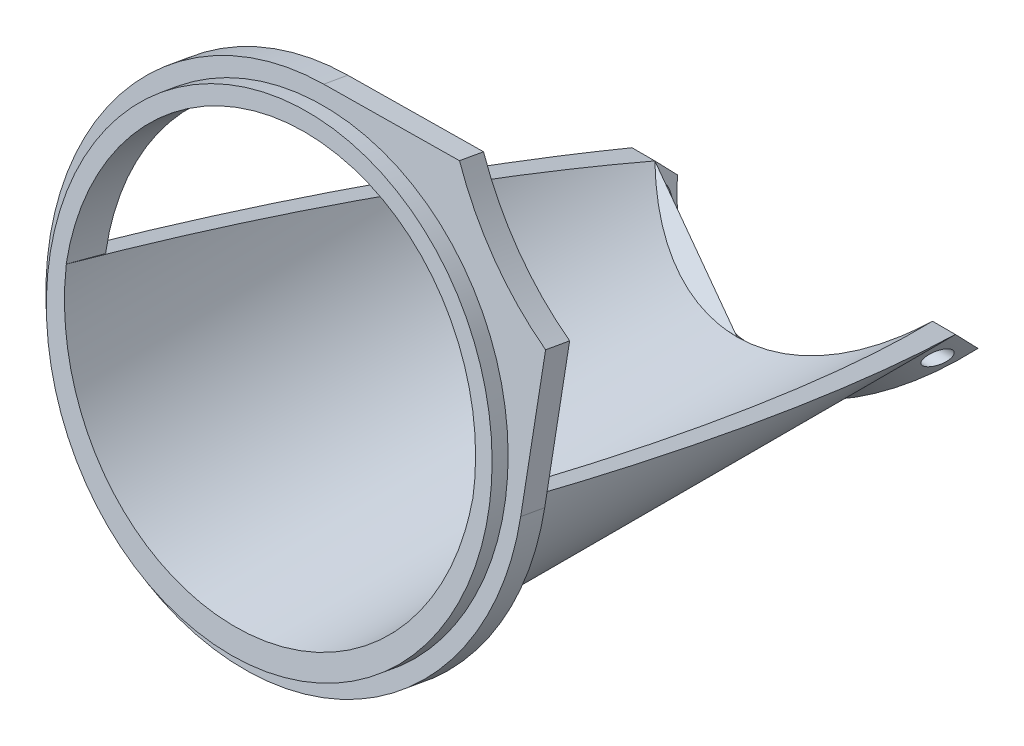
from build123d import *

# Parameters (mm, degrees)
MAIN_DEPTH                = 90
TOPSUPPORT_DEPTH          = 99.336158152
TOPSUPPORT_DEPTH_BACK     = 99.336158152
BACK_EXTRUSION_DEPTH      = 99.336158152
BACK_EXTRUSION_DEPTH_BACK = 99.336158152
BACK_DEPTH                = 4
SKETCH8_R                 = 1.25
ROLLINGHOLESUPPORT_DEPTH  = 25
SKETCH3_R                 = 27
SKETCH3_R_2               = 25
CIRCLEFIX_DEPTH           = 2
SKETCH5_R                 = 25
TRIANGLEFIX_DEPTH         = 3
SKETCH12_R                = 52.533480643
CUT_EXTRUDE2_DEPTH        = 85.444365438


with BuildPart() as part:
    # Sketch1 → Main (new body)
    with BuildSketch(Plane.XY):
        with BuildLine():
            Line((25, 27), (25, 29))
            Line((25, 29), (26.925824036, 29))
            ThreePointArc((26.925824036, 29), (0, 0), (-26.925824036, 29))
            Line((-26.925824036, 29), (-25, 29))
            Line((-25, 29), (-25, 27))
            ThreePointArc((-25, 27), (0, 2), (25, 27))
        make_face()
    extrude(amount=MAIN_DEPTH)

    # Sketch11 → TopSupport (cut, two sides: drawn at the far end of the back side and taken through both)
    with BuildSketch(Plane(origin=(0, 0, 0), x_dir=(0, 0, -1), z_dir=(1, 0, 0)).offset(-TOPSUPPORT_DEPTH_BACK)):
        Polygon((-84.886517559, 29), (0, 29), (0, 3.112986155), (-85.415498502, 26), align=None)
    extrude(amount=TOPSUPPORT_DEPTH + TOPSUPPORT_DEPTH_BACK, mode=Mode.SUBTRACT)

    # Sketch6 → Back-Extrusion (cut, two sides: drawn at the far end of the back side and taken through both)
    with BuildSketch(Plane(origin=(0, 0, 0), x_dir=(0, 0, -1), z_dir=(1, 0, 0)).offset(-BACK_EXTRUSION_DEPTH_BACK)):
        Polygon((0, 29), (0, 0), (-30, 0), align=None)
    extrude(amount=BACK_EXTRUSION_DEPTH + BACK_EXTRUSION_DEPTH_BACK, mode=Mode.SUBTRACT)

    # Sketch7 → Back (add)
    with BuildSketch(Plane(origin=(0, 14.991384262, 14.491671453), x_dir=(1, 0, 0), z_dir=(0, -0.7189883760491118, -0.6950220968474751))):
        with BuildLine():
            Line((19.880970173, 9.007093118), (17.066135327, 9.007093118))
            ThreePointArc((17.066135327, 9.007093118), (0, 18.69204493), (-17.066135327, 9.007093118))
            Line((-17.066135327, 9.007093118), (-19.880970173, 9.007093118))
            add(Edge.make_bspline(
                [(19.880970173, 9.007093118), (0, 40.117630414), (-19.880970173, 9.007093118)],
                knots=[5.456476318, 5.456476318, 5.456476318, 7.109894296, 7.109894296, 7.109894296], degree=2, weights=[1, 0.677300641, 1]))
        make_face()
    extrude(amount=BACK_DEPTH)

    # Sketch8 → RollingHoleSupport (cut, symmetric)
    with BuildSketch(Plane(origin=(0, 0, 0), x_dir=(0, 0, -1), z_dir=(1, 0, 0))):
        with Locations((-21.375093453, 5.555723522)):
            Circle(SKETCH8_R)
    extrude(amount=ROLLINGHOLESUPPORT_DEPTH, both=True, mode=Mode.SUBTRACT)

    # Sketch3 → CircleFix (add)
    with BuildSketch(Plane(origin=(0, 0.398226786, 89.929781873), x_dir=(1, 0, 0), z_dir=(0, 0.17364817766693072, 0.984807753012208))):
        with Locations((0, 25.80563308)):
            Circle(SKETCH3_R)
        with Locations((0, 25.80563308)):
            Circle(SKETCH3_R_2, mode=Mode.SUBTRACT)
    extrude(amount=-CIRCLEFIX_DEPTH)

    # Sketch5 → TriangleFix (add)
    with BuildSketch(Plane(origin=(0, 15.043610094, 85.316552429), x_dir=(-1, 0, 0), z_dir=(0, 0.17364817766693072, 0.9848077530122081))):
        with BuildLine():
            Line((0.29697859, -39.580146501), (-16.358158426, -39.750714725))
            ThreePointArc((-16.358158426, -39.750714725), (-21.920310217, -32.501977383), (-29.169047558, -26.939825592))
            Line((-29.169047558, -26.939825592), (-28.998479335, -10.284688576))
            ThreePointArc((-28.998479335, -10.284688576), (20.506096654, 9.924429488), (0.29697859, -39.580146501))
        make_face()
        with Locations((0, -10.581667167)):
            Circle(SKETCH5_R, mode=Mode.SUBTRACT)
    extrude(amount=-TRIANGLEFIX_DEPTH)

    # Sketch12 → Cut-Extrude2 (cut, through all)
    with BuildSketch(Plane(origin=(0, 15.39090645, 87.286167935), x_dir=(1, 0, 0), z_dir=(0, 0.17364817766693072, 0.9848077530122081))):
        with Locations((0, 15.306580729)):
            Circle(SKETCH12_R)
    extrude(amount=CUT_EXTRUDE2_DEPTH, mode=Mode.SUBTRACT)


solid = part.part
